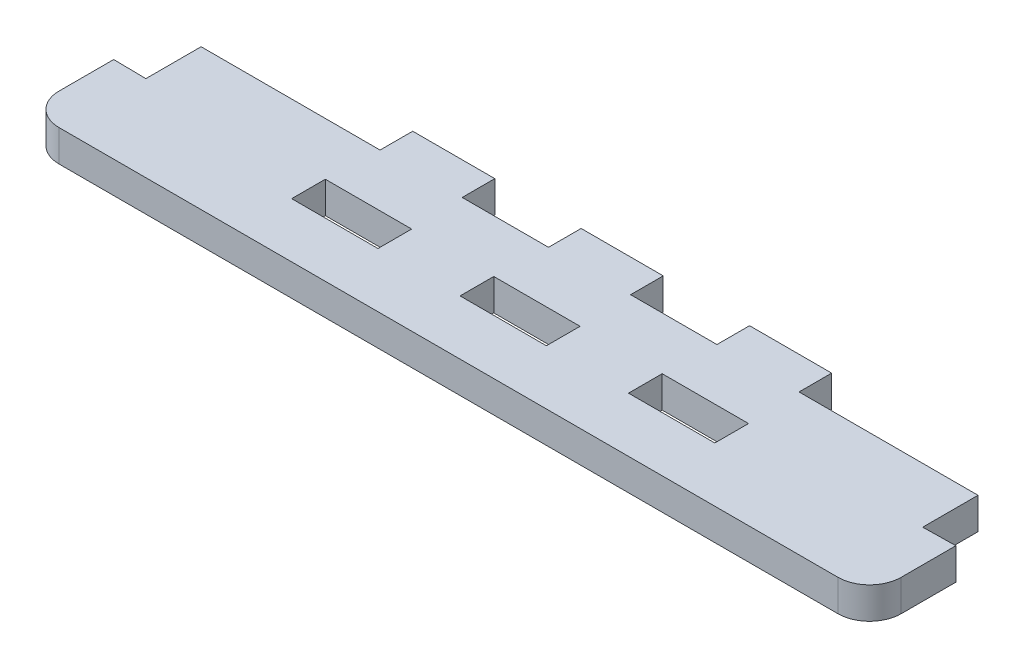
from build123d import *

# Parameters (mm, degrees)
SKETCH1_W           = 80
SKETCH1_H           = 16.5
BOSS_EXTRUDE1_DEPTH = 3
SKETCH3_W           = 8.2
SKETCH3_H           = 3.2
CUT_EXTRUDE1_DEPTH  = 4
FILLET1_R           = 3


with BuildPart() as part:
    # Sketch1 → Boss-Extrude1 (new body)
    with BuildSketch(Plane(origin=(0, 0, 0), x_dir=(1, 0, 0), z_dir=(0, 1, 0))):
        with Locations((40, -8.25)):
            Rectangle(SKETCH1_W, SKETCH1_H)
    extrude(amount=-BOSS_EXTRUDE1_DEPTH)

    # Sketch3 → Cut-Extrude1 (cut, through all)
    with BuildSketch(Plane(origin=(0, 0, 0), x_dir=(1, 0, 0), z_dir=(0, 1, 0))):
        with Locations((24, -9.7)):
            Rectangle(SKETCH3_W, SKETCH3_H)
        with Locations((40, -9.7)):
            Rectangle(SKETCH3_W, SKETCH3_H)
        with Locations((32, -1.5)):
            Rectangle(SKETCH3_W, SKETCH3_H)
        with Locations((56, -9.7)):
            Rectangle(SKETCH3_W, SKETCH3_H)
        with Locations((48, -1.5)):
            Rectangle(SKETCH3_W, SKETCH3_H)
        Polygon((76.9, -3.1), (76.9, -8.351680555), (80.1, -8.298347221), (80.1, 0.1), (59.9, 0.1), (59.9, -3.1), align=None)
        Polygon((-0.1, -8.298347221), (3.1, -8.351680555), (3.1, -3.1), (20.1, -3.1), (20.1, 0.1), (-0.1, 0.1), align=None)
    extrude(amount=-CUT_EXTRUDE1_DEPTH, mode=Mode.SUBTRACT)

    # Fillet1
    fillet1_edges = [part.edges().sort_by_distance(p)[0] for p in [
        (80, -1.5, 16.5),
        (0, -1.5, 16.5),
    ]]
    fillet(fillet1_edges, radius=FILLET1_R)


solid = part.part
